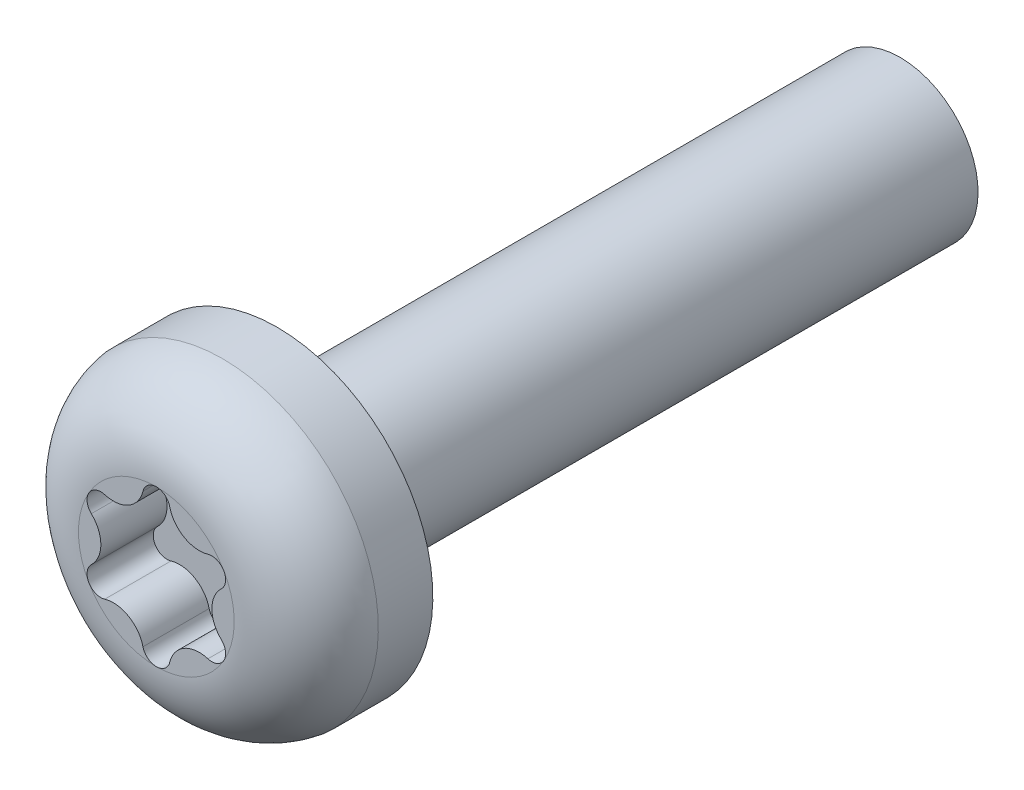
from build123d import *

# Parameters (mm, degrees)
ENL_V_MAT_EXTRU_1_DEPTH = 1.7


with BuildPart() as part:
    # Esquisse1 → Révolution1 (revolve)
    with BuildSketch(Plane(origin=(0, 0, 0), x_dir=(0, 0, -1), z_dir=(1, 0, 0))):
        with BuildLine():
            Line((-3.1, 0), (-3.1, 2))
            ThreePointArc((-3.1, 2), (-2.617577029, 3.312440475), (-1.4, 4))
            Line((-1.4, 4), (0, 4))
            Line((0, 4), (0, 2))
            Line((0, 2), (16, 2))
            Line((16, 2), (16, 0))
            Line((16, 0), (-3.1, 0))
        make_face()
    revolve(axis=Axis((0, 0, 3.1), (0, 0, 1)))

    # Esquisse2 → Enlèv. mat.-Extru.1 (cut)
    with BuildSketch(Plane.XY.offset(3.1)):
        with BuildLine():
            ThreePointArc((-0.343897346, 1.728888708), (0, 2), (0.343897346, 1.728888708))
            ThreePointArc((0.343897346, 1.728888708), (0.712882715, 1.234749083), (1.325312868, 1.162268192))
            ThreePointArc((1.325312868, 1.162268192), (1.732050808, 1), (1.669210214, 0.566620516))
            ThreePointArc((1.669210214, 0.566620516), (1.42576543, 0), (1.669210214, -0.566620516))
            ThreePointArc((1.669210214, -0.566620516), (1.732050808, -1), (1.325312868, -1.162268192))
            ThreePointArc((1.325312868, -1.162268192), (0.712882715, -1.234749083), (0.343897346, -1.728888708))
            ThreePointArc((0.343897346, -1.728888708), (0, -2), (-0.343897346, -1.728888708))
            ThreePointArc((-0.343897346, -1.728888708), (-0.712882715, -1.234749083), (-1.325312868, -1.162268192))
            ThreePointArc((-1.325312868, -1.162268192), (-1.732050808, -1), (-1.669210214, -0.566620516))
            ThreePointArc((-1.669210214, -0.566620516), (-1.42576543, 0), (-1.669210214, 0.566620516))
            ThreePointArc((-1.669210214, 0.566620516), (-1.732050808, 1), (-1.325312868, 1.162268192))
            ThreePointArc((-1.325312868, 1.162268192), (-0.712882715, 1.234749083), (-0.343897346, 1.728888708))
        make_face()
    extrude(amount=-ENL_V_MAT_EXTRU_1_DEPTH, mode=Mode.SUBTRACT)


solid = part.part
